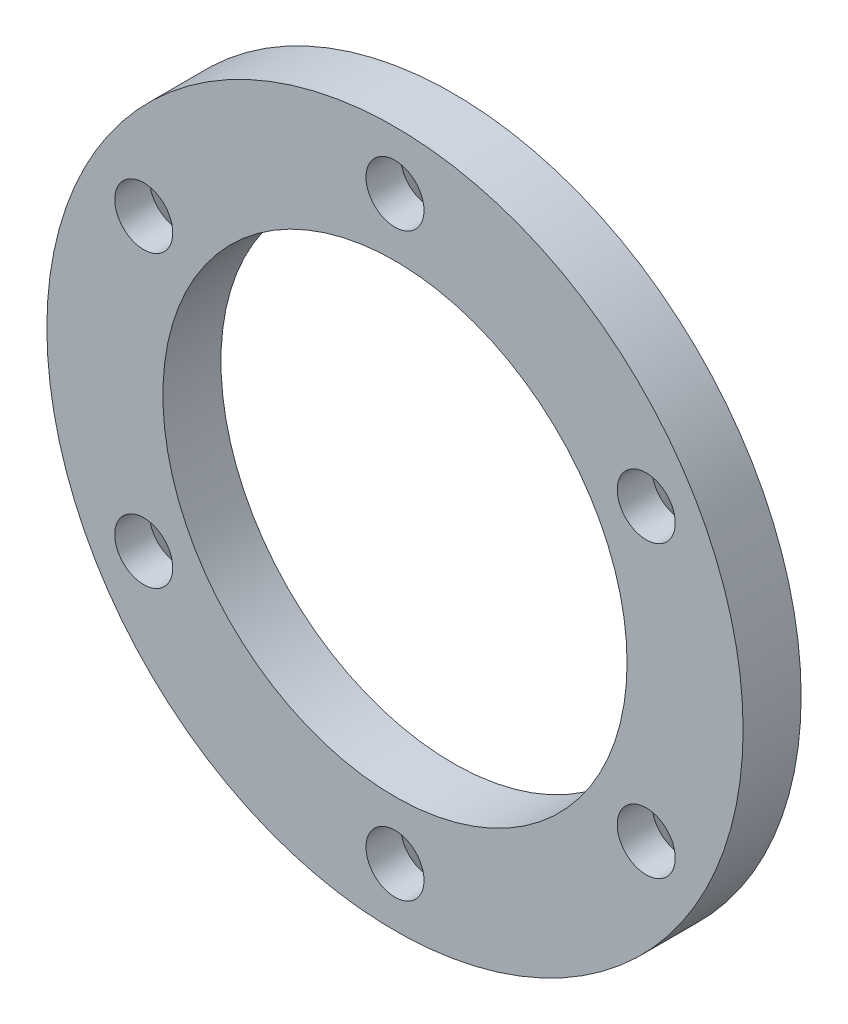
from build123d import *

# Parameters (mm, degrees)
SKETCH1_R           = 30
SKETCH1_R_2         = 20
SKETCH1_R_3         = 2.5
BOSS_EXTRUDE1_DEPTH = 5
CHAMFER1_SIZE       = 2


with BuildPart() as part:
    # Sketch1 → Boss-Extrude1 (new body)
    with BuildSketch(Plane.XY):
        Circle(SKETCH1_R)
        Circle(SKETCH1_R_2, mode=Mode.SUBTRACT)
        with Locations((0, 25)):
            Circle(SKETCH1_R_3, mode=Mode.SUBTRACT)
        with Locations((21.650635095, 12.5)):
            Circle(SKETCH1_R_3, mode=Mode.SUBTRACT)
        with Locations((21.650635095, -12.5)):
            Circle(SKETCH1_R_3, mode=Mode.SUBTRACT)
        with Locations((0, -25)):
            Circle(SKETCH1_R_3, mode=Mode.SUBTRACT)
        with Locations((-21.650635095, -12.5)):
            Circle(SKETCH1_R_3, mode=Mode.SUBTRACT)
        with Locations((-21.650635095, 12.5)):
            Circle(SKETCH1_R_3, mode=Mode.SUBTRACT)
    extrude(amount=BOSS_EXTRUDE1_DEPTH)

    # Chamfer1
    chamfer1_edges = [part.edges().sort_by_distance(p)[0] for p in [
        (19.150635095, -12.5, 0),
        (-2.5, -25, 0),
        (-24.150635095, -12.5, 0),
        (-24.150635095, 12.5, 0),
        (-2.5, 25, 0),
        (19.150635095, 12.5, 0),
    ]]
    chamfer(chamfer1_edges, length=CHAMFER1_SIZE)


solid = part.part
